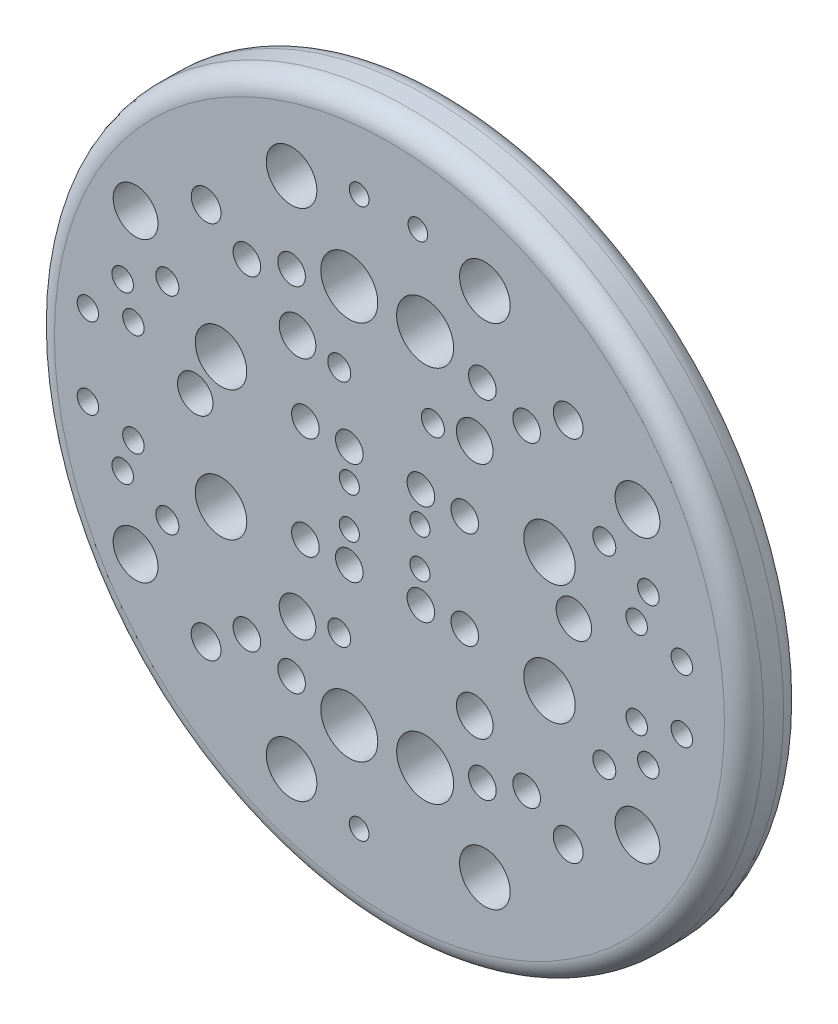
from build123d import *

# Parameters (mm, degrees)
SKETCH1_R           = 9
BOSS_EXTRUDE1_DEPTH = 1.5
FILLET1_R           = 0.5
SKETCH2_R           = 0.249558175
SKETCH2_R_2         = 0.641721022
SKETCH2_R_3         = 0.350217157
SKETCH2_R_4         = 0.378137739
SKETCH2_R_5         = 0.464834359
SKETCH2_R_6         = 0.653742585
SKETCH2_R_7         = 0.291468835
SKETCH2_R_8         = 0.568800221
SKETCH2_R_9         = 0.272679001
SKETCH2_R_10        = 0.271472764
SKETCH2_R_11        = 0.449886638
SKETCH2_R_12        = 0.722944318
SKETCH2_R_13        = 0.254625476
CUT_EXTRUDE1_DEPTH  = 1.5


with BuildPart() as part:
    # Sketch1 → Boss-Extrude1 (new body)
    with BuildSketch(Plane.XY):
        Circle(SKETCH1_R)
    extrude(amount=BOSS_EXTRUDE1_DEPTH)

    # Fillet1
    fillet1_edges = [part.edges().sort_by_distance(p)[0] for p in [
        (-9, 0, 0),
        (-9, 0, 1.5),
    ]]
    fillet(fillet1_edges, radius=FILLET1_R)

    # Sketch2 → Cut-Extrude1 (cut)
    with BuildSketch(Plane(origin=(0, 0, 0), x_dir=(-1, 0, 0), z_dir=(0, 0, -1))):
        with Locations((0.768880069, 6.970338983)):
            Circle(SKETCH2_R)
        with Locations((2.483104484, 6.516573697)):
            Circle(SKETCH2_R_2)
        with Locations((3.6175177, 4.121701352)):
            Circle(SKETCH2_R_3)
        with Locations((4.651094186, 4.802349281)):
            Circle(SKETCH2_R_4)
        with Locations((2.483104484, 4.471918509)):
            Circle(SKETCH2_R_3)
        with Locations((2.331849389, 3.088124866)):
            Circle(SKETCH2_R_5)
        with Locations((2.132887327, 1.298272903)):
            Circle(SKETCH2_R_3)
        with Locations((4.272956447, 1.64849006)):
            Circle(SKETCH2_R_6)
        with Locations((5.634252306, 2.623290507)):
            Circle(SKETCH2_R_7)
        with Locations((6.440946149, 3.771484195)):
            Circle(SKETCH2_R_8)
        with Locations((6.768665522, 2.104966745)):
            Circle(SKETCH2_R_9)
        with Locations((6.495986521, 1.298272903)):
            Circle(SKETCH2_R_9)
        with Locations((7.650986913, 1.025593902)):
            Circle(SKETCH2_R_10)
        with Locations((4.926699032, 0.516788243)):
            Circle(SKETCH2_R_11)
        with Locations((1.018438244, 4.822135666)):
            Circle(SKETCH2_R_12)
        with Locations((1.27306372, 2.914759342)):
            Circle(SKETCH2_R_7)
        with Locations((1.018438244, 1.298272903)):
            Circle(SKETCH2_R_3)
        with Locations((1.018438244, 0.516788243)):
            Circle(SKETCH2_R_13)
        with Locations((-0.773334123, 0.489329569)):
            Circle(SKETCH2_R_13)
        with Locations((-0.797280796, 1.27044725)):
            Circle(SKETCH2_R_3)
        with Locations((-1.911206542, 1.236297701)):
            Circle(SKETCH2_R_3)
        with Locations((-1.101319949, 2.878372227)):
            Circle(SKETCH2_R_7)
        with Locations((-2.164920779, 3.01921246)):
            Circle(SKETCH2_R_5)
        with Locations((-4.679759619, 0.369570539)):
            Circle(SKETCH2_R_11)
        with Locations((-4.061002244, 1.520773249)):
            Circle(SKETCH2_R_6)
        with Locations((-5.451529208, 2.453402377)):
            Circle(SKETCH2_R_7)
        with Locations((-6.272256856, 1.102601268)):
            Circle(SKETCH2_R_9)
        with Locations((-7.418359291, 0.794658172)):
            Circle(SKETCH2_R_10)
        with Locations((-6.569526956, 1.900560716)):
            Circle(SKETCH2_R_9)
        with Locations((-6.293027801, 3.576337734)):
            Circle(SKETCH2_R_8)
        with Locations((-4.535604663, 4.661564341)):
            Circle(SKETCH2_R_4)
        with Locations((-3.481656757, 4.012907446)):
            Circle(SKETCH2_R_3)
        with Locations((-2.358507796, 4.397721443)):
            Circle(SKETCH2_R_3)
        with Locations((-2.42116122, 6.441416476)):
            Circle(SKETCH2_R_2)
        with Locations((-0.721646312, 6.947496864)):
            Circle(SKETCH2_R)
        with Locations((-0.905260895, 4.792655232)):
            Circle(SKETCH2_R_12)
        with Locations((7.650986913, -1.025593902)):
            Circle(SKETCH2_R_10)
        with Locations((6.768665522, -2.104966745)):
            Circle(SKETCH2_R_9)
        with Locations((6.495986521, -1.298272903)):
            Circle(SKETCH2_R_9)
        with Locations((6.440946149, -3.771484195)):
            Circle(SKETCH2_R_8)
        with Locations((5.634252306, -2.623290507)):
            Circle(SKETCH2_R_7)
        with Locations((4.272956447, -1.64849006)):
            Circle(SKETCH2_R_6)
        with Locations((2.132887327, -1.298272903)):
            Circle(SKETCH2_R_3)
        with Locations((2.331849389, -3.088124866)):
            Circle(SKETCH2_R_5)
        with Locations((2.483104484, -4.471918509)):
            Circle(SKETCH2_R_3)
        with Locations((3.6175177, -4.121701352)):
            Circle(SKETCH2_R_3)
        with Locations((4.651094186, -4.802349281)):
            Circle(SKETCH2_R_4)
        with Locations((0.768880069, -6.970338983)):
            Circle(SKETCH2_R)
        with Locations((2.483104484, -6.516573697)):
            Circle(SKETCH2_R_2)
        with Locations((1.018438244, -4.822135666)):
            Circle(SKETCH2_R_12)
        with Locations((1.27306372, -2.914759342)):
            Circle(SKETCH2_R_7)
        with Locations((1.018438244, -1.298272903)):
            Circle(SKETCH2_R_3)
        with Locations((1.018438244, -0.516788243)):
            Circle(SKETCH2_R_13)
        with Locations((-0.797280796, -1.27044725)):
            Circle(SKETCH2_R_3)
        with Locations((-0.773334123, -0.489329569)):
            Circle(SKETCH2_R_13)
        with Locations((-1.911206542, -1.236297701)):
            Circle(SKETCH2_R_3)
        with Locations((-2.358507796, -4.397721443)):
            Circle(SKETCH2_R_3)
        with Locations((-0.905260895, -4.792655232)):
            Circle(SKETCH2_R_12)
        with Locations((-3.481656757, -4.012907446)):
            Circle(SKETCH2_R_3)
        with Locations((-2.164920779, -3.01921246)):
            Circle(SKETCH2_R_5)
        with Locations((-4.061002244, -1.520773249)):
            Circle(SKETCH2_R_6)
        with Locations((-5.451529208, -2.453402377)):
            Circle(SKETCH2_R_7)
        with Locations((-6.272256856, -1.102601268)):
            Circle(SKETCH2_R_9)
        with Locations((-7.418359291, -0.794658172)):
            Circle(SKETCH2_R_10)
        with Locations((-6.569526956, -1.900560716)):
            Circle(SKETCH2_R_9)
        with Locations((-6.293027801, -3.576337734)):
            Circle(SKETCH2_R_8)
        with Locations((-4.535604663, -4.661564341)):
            Circle(SKETCH2_R_4)
        with Locations((-2.42116122, -6.441416476)):
            Circle(SKETCH2_R_2)
    extrude(amount=-CUT_EXTRUDE1_DEPTH, mode=Mode.SUBTRACT)


solid = part.part
